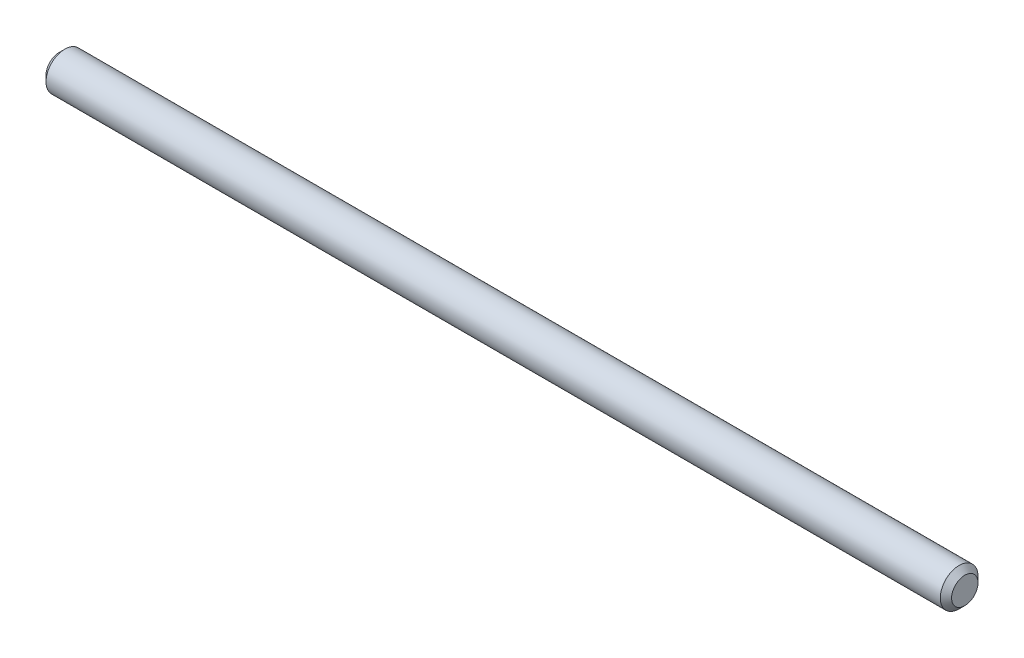
from build123d import *

# Parameters (mm, degrees)
SKETCH2_R                = 3.175
BOSS_EXTRUDE1_DEPTH      = 76.2
BOSS_EXTRUDE1_DEPTH_BACK = 76.2
CHAMFER1_SIZE            = 0.9525


with BuildPart() as part:
    # Sketch2 → Boss-Extrude1 (new body, two sides)
    with BuildSketch(Plane(origin=(0, 0, 0), x_dir=(0, 0, -1), z_dir=(1, 0, 0))) as boss_extrude1_sk:
        Circle(SKETCH2_R)
    extrude(amount=BOSS_EXTRUDE1_DEPTH)
    extrude(boss_extrude1_sk.sketch, amount=-BOSS_EXTRUDE1_DEPTH_BACK)

    # Chamfer1
    chamfer1_edges = [part.edges().sort_by_distance(p)[0] for p in [
        (-76.2, 0, 3.175),
        (76.2, 0, 3.175),
    ]]
    chamfer(chamfer1_edges, length=CHAMFER1_SIZE)


solid = part.part
